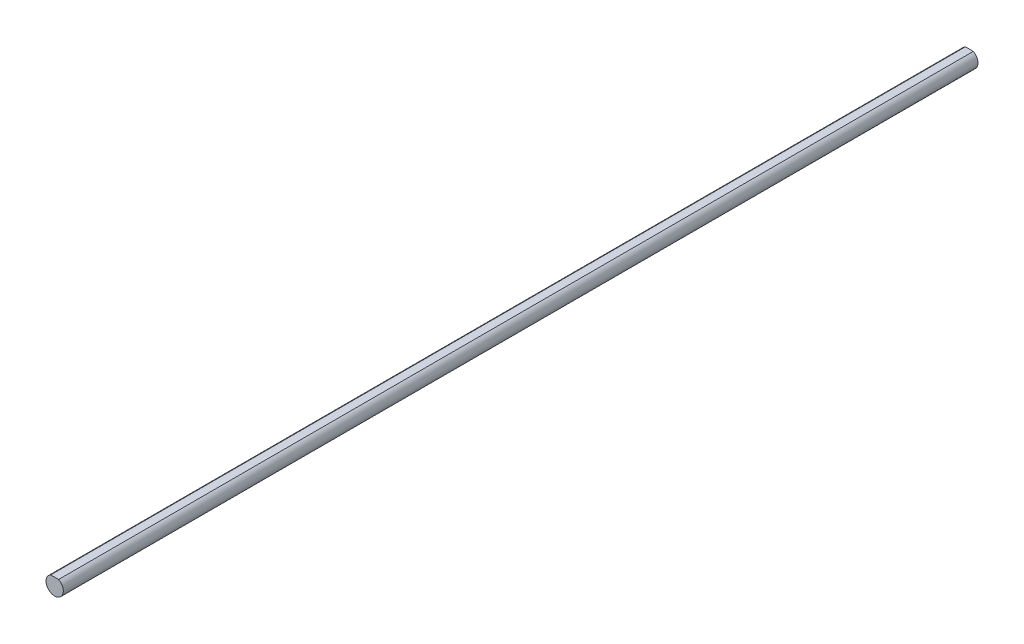
from build123d import *

# Parameters (mm, degrees)
BOSS_EXTRUDE1_DEPTH = 250


with BuildPart() as part:
    # Sketch1 → Boss-Extrude1 (new body)
    with BuildSketch(Plane(origin=(0, 0, -125), x_dir=(-1, 0, 0), z_dir=(0, 0, -1))):
        with BuildLine():
            Line((1.087761463, 2.1), (-1.087761463, 2.1))
            ThreePointArc((-1.087761463, 2.1), (0, -2.365), (1.087761463, 2.1))
        make_face()
    extrude(amount=-BOSS_EXTRUDE1_DEPTH)


solid = part.part
